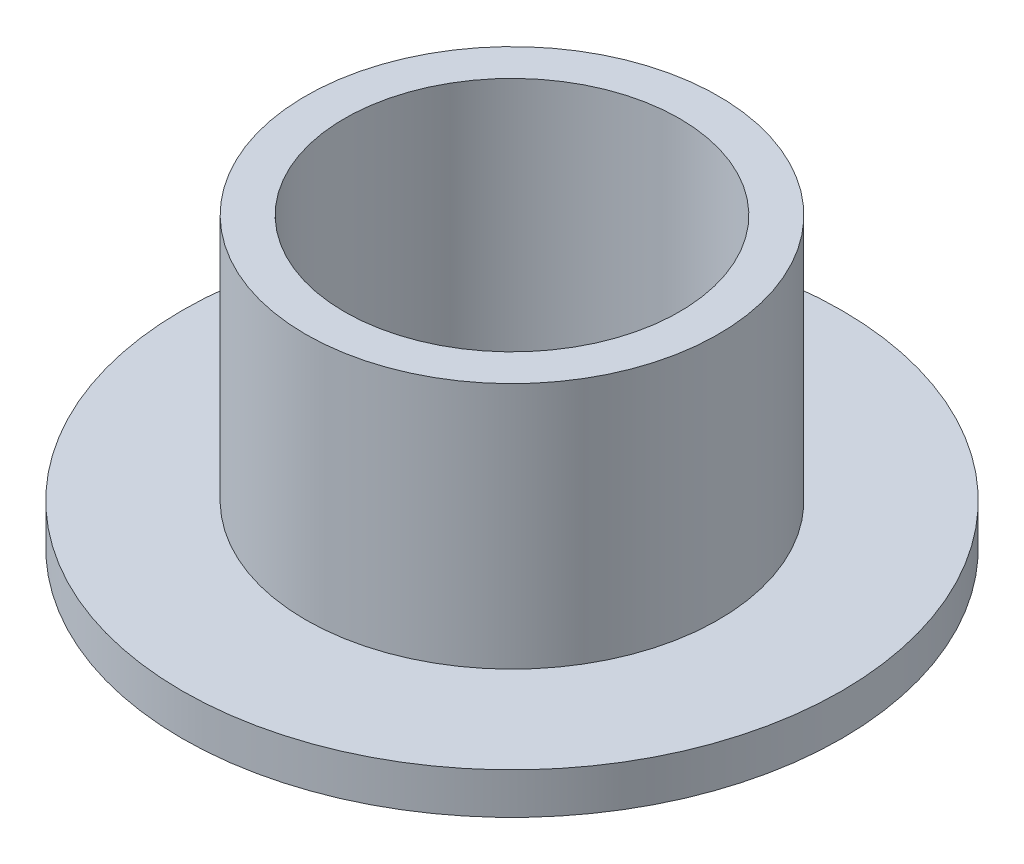
from build123d import *

# Parameters (mm, degrees)
SKETCH2_R           = 3.9751
SKETCH2_R_2         = 3.2258
BOSS_EXTRUDE1_DEPTH = 12.7
SKETCH3_R           = 6.35
SKETCH3_R_2         = 3.9751
BOSS_EXTRUDE2_DEPTH = 0.79375
CUT_EXTRUDE1_START  = 4.7625
SKETCH4_R           = 6.35
CUT_EXTRUDE1_DEPTH  = 8.14375


with BuildPart() as part:
    # Sketch2 → Boss-Extrude1 (new body)
    with BuildSketch(Plane(origin=(0, 0, 0), x_dir=(1, 0, 0), z_dir=(0, 1, 0))):
        Circle(SKETCH2_R)
        Circle(SKETCH2_R_2, mode=Mode.SUBTRACT)
    extrude(amount=BOSS_EXTRUDE1_DEPTH)

    # Sketch3 → Boss-Extrude2 (add)
    with BuildSketch(Plane(origin=(0, 0, 0), x_dir=(1, 0, 0), z_dir=(0, 1, 0))):
        Circle(SKETCH3_R)
        Circle(SKETCH3_R_2, mode=Mode.SUBTRACT)
    extrude(amount=BOSS_EXTRUDE2_DEPTH)

    # Sketch4 → Cut-Extrude1 (cut, through all)
    with BuildSketch(Plane(origin=(0, 0.79375, 0), x_dir=(1, 0, 0), z_dir=(0, 1, 0)).offset(CUT_EXTRUDE1_START)):
        Circle(SKETCH4_R)
    extrude(amount=CUT_EXTRUDE1_DEPTH, mode=Mode.SUBTRACT)


solid = part.part
